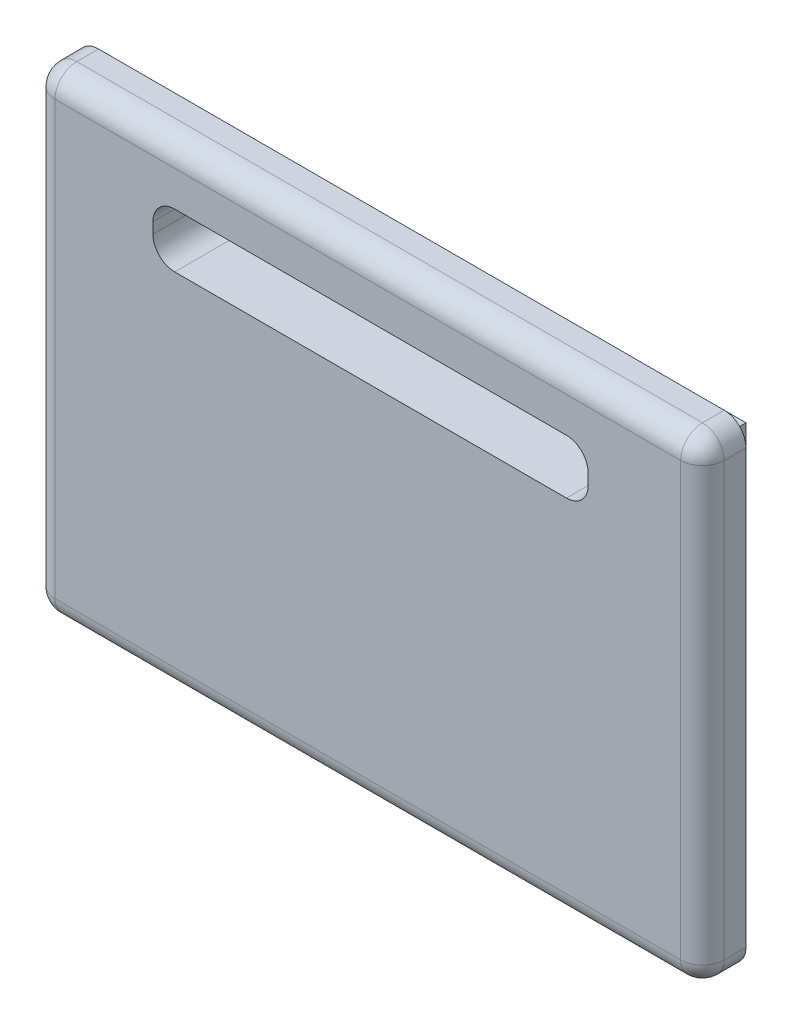
from build123d import *

# Parameters (mm, degrees)
ESQUISSE1_W             = 61.5
ESQUISSE1_H             = 43.75
BOSS_EXTRU_1_DEPTH      = 4
ESQUISSE2_W             = 53.5
ESQUISSE2_H             = 35.75
BOSS_EXTRU_2_DEPTH      = 4
CONG_1_R                = 2
ENL_V_MAT_EXTRU_1_REACH = 10
ESQUISSE3_W             = 40
ESQUISSE3_H             = 5
CONG_2_R                = 2


with BuildPart() as part:
    # Esquisse1 → Boss.-Extru.1 (new body)
    with BuildSketch(Plane.XY):
        with Locations((9.227308767, 0.94004118)):
            Rectangle(ESQUISSE1_W, ESQUISSE1_H)
    extrude(amount=BOSS_EXTRU_1_DEPTH)

    # Esquisse2 → Boss.-Extru.2 (add)
    with BuildSketch(Plane(origin=(0, 0, 0), x_dir=(-1, 0, 0), z_dir=(0, 0, -1))):
        with Locations((-9.227308767, 0.94004118)):
            Rectangle(ESQUISSE2_W, ESQUISSE2_H)
    extrude(amount=BOSS_EXTRU_2_DEPTH)

    # Congé1
    cong_1_edges = [part.edges().sort_by_distance(p)[0] for p in [
        (39.977308767, 0.94004118, 4),
        (9.227308767, 22.81504118, 4),
        (-21.522691233, 0.94004118, 4),
        (-21.522691233, 22.81504118, 2),
        (39.977308767, 22.81504118, 2),
        (39.977308767, -20.93495882, 2),
        (-21.522691233, -20.93495882, 2),
        (9.227308767, -20.93495882, 4),
    ]]
    fillet(cong_1_edges, radius=CONG_1_R)

    # Esquisse3 → Enlèv. mat.-Extru.1 (cut, up to next)
    with BuildSketch(Plane.XY.offset(4), mode=Mode.PRIVATE) as enl_v_mat_extru_1_sk1:
        with Locations((9.477308767, 15.072235538)):
            Rectangle(ESQUISSE3_W, ESQUISSE3_H)
    enl_v_mat_extru_1_tool1 = extrude(enl_v_mat_extru_1_sk1.sketch, amount=-ENL_V_MAT_EXTRU_1_REACH, mode=Mode.PRIVATE) & part.part
    add(enl_v_mat_extru_1_tool1.solids().sort_by_distance((9.477309, 15.072236, 4))[0], mode=Mode.SUBTRACT)

    # Congé2
    cong_2_edges = [part.edges().sort_by_distance(p)[0] for p in [
        (-10.522691233, 12.572235538, 0),
        (-10.522691233, 17.572235538, 0),
        (29.477308767, 17.572235538, 0),
        (29.477308767, 12.572235538, 0),
    ]]
    fillet(cong_2_edges, radius=CONG_2_R)


solid = part.part
